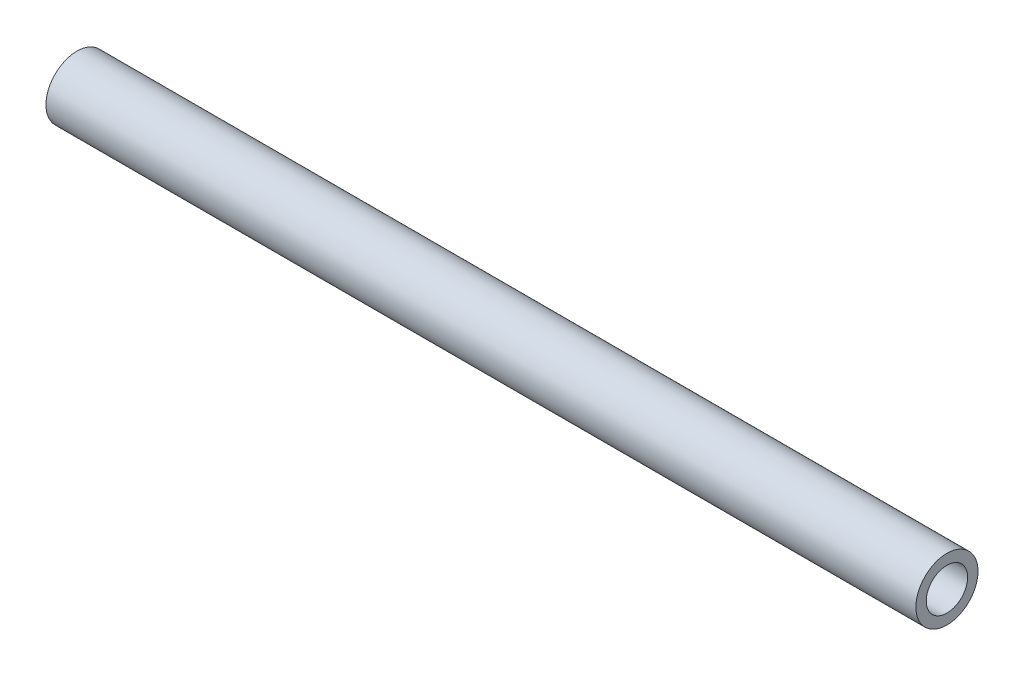
from build123d import *

# Parameters (mm, degrees)
SKETCH1_R           = 9.525
SKETCH1_R_2         = 6.35
BOSS_EXTRUDE1_DEPTH = 266.7


with BuildPart() as part:
    # Sketch1 → Boss-Extrude1 (new body)
    with BuildSketch(Plane(origin=(0, 0, 0), x_dir=(0, 0, -1), z_dir=(1, 0, 0))):
        Circle(SKETCH1_R)
        Circle(SKETCH1_R_2, mode=Mode.SUBTRACT)
    extrude(amount=BOSS_EXTRUDE1_DEPTH)


solid = part.part
